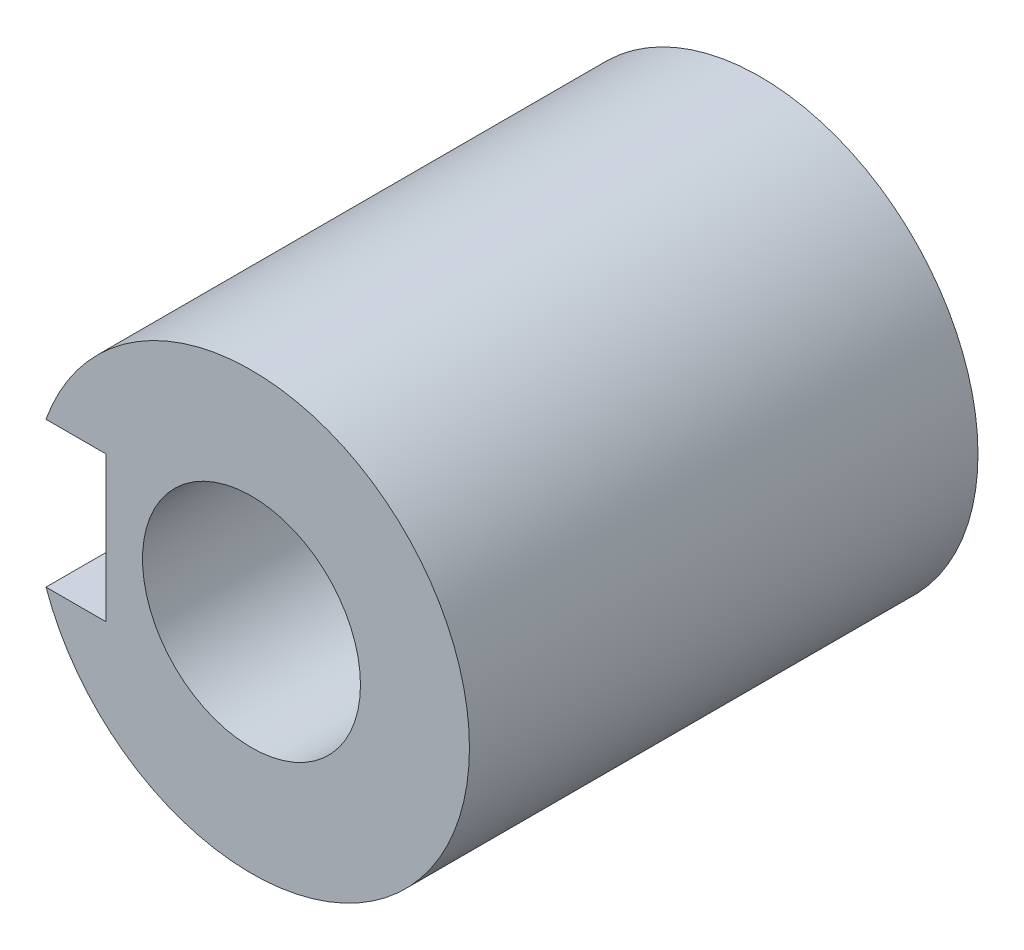
from build123d import *

# Parameters (mm, degrees)
EXTRUDE_1_DEPTH     = 28
CUT_EXTRUDE_1_DEPTH = 10
SKETCH_3_R          = 6
CUT_EXTRUDE_2_DEPTH = 18


with BuildPart() as part:
    # Эскиз1 → Бобышка-Вытянуть1 (new body)
    with BuildSketch(Plane(origin=(0, 0, -1), x_dir=(-1, 0, 0), z_dir=(0, 0, -1))):
        with BuildLine():
            Line((11.313708499, 4), (8, 4))
            Line((8, 4), (8, -4))
            Line((8, -4), (11.313708499, -4))
            ThreePointArc((11.313708499, -4), (-12, 0), (11.313708499, 4))
        make_face()
    extrude(amount=-EXTRUDE_1_DEPTH)

    # Эскиз2 → Вырез-Вытянуть1 (cut)
    with BuildSketch(Plane(origin=(0, 0, -1), x_dir=(-1, 0, 0), z_dir=(0, 0, -1))):
        with BuildLine():
            Line((-3.31662479, 5), (3.31662479, 5))
            ThreePointArc((3.31662479, 5), (5.868522172, 3.577282395), (6, 0.658546503))
            Line((6, 0.658546503), (6, -0.658546503))
            ThreePointArc((6, -0.658546503), (5.868522172, -3.577282395), (3.31662479, -5))
            Line((3.31662479, -5), (-3.31662479, -5))
            ThreePointArc((-3.31662479, -5), (-5.868522172, -3.577282395), (-6, -0.658546503))
            Line((-6, -0.658546503), (-6, 0.658546503))
            ThreePointArc((-6, 0.658546503), (-5.868522172, 3.577282395), (-3.31662479, 5))
        make_face()
    extrude(amount=-CUT_EXTRUDE_1_DEPTH, mode=Mode.SUBTRACT)

    # Эскиз3 → Вырез-Вытянуть2 (cut)
    with BuildSketch(Plane.XY.offset(27)):
        Circle(SKETCH_3_R)
    extrude(amount=-CUT_EXTRUDE_2_DEPTH, mode=Mode.SUBTRACT)


solid = part.part
